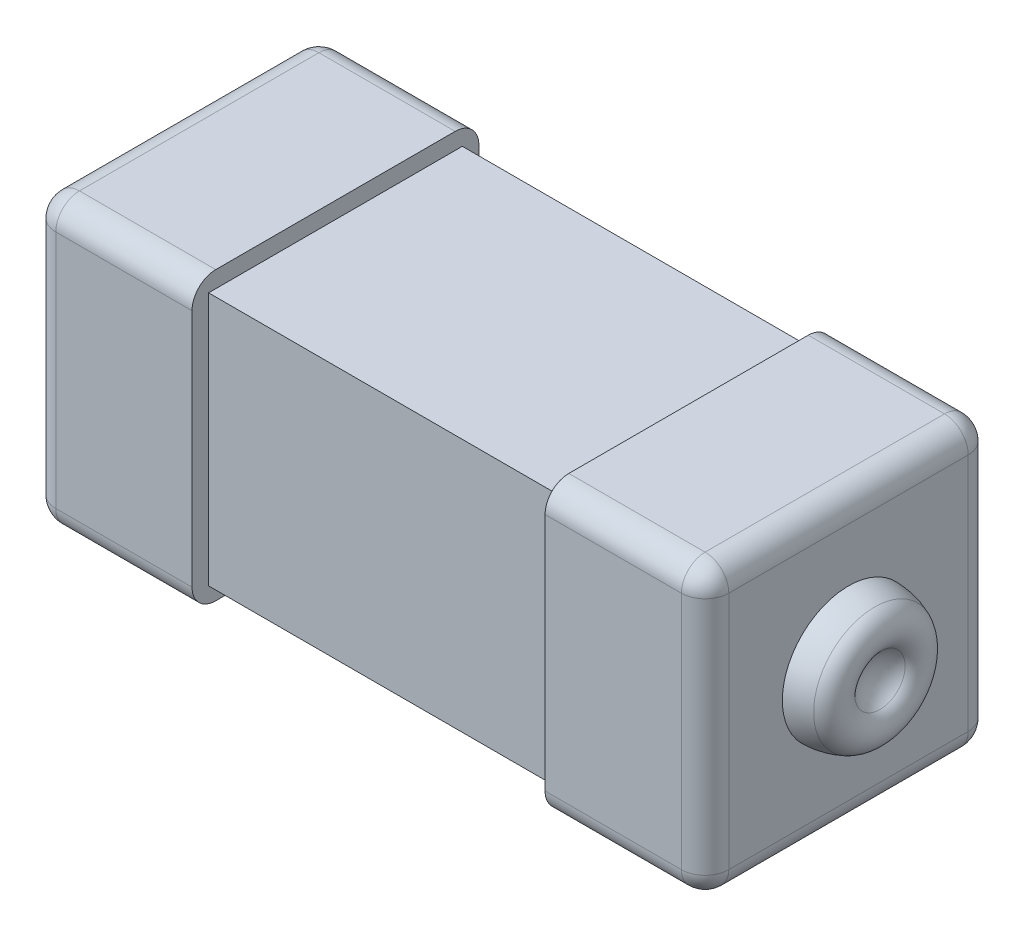
from build123d import *

# Parameters (mm, degrees)
SKETCH1_W            = 2.3
SKETCH1_H            = 2.3
BOSS_EXTRUDE1_DEPTH  = 1.6
SKETCH4_W            = 2.6
SKETCH4_H            = 2.6
BOSS_EXTRUDE2_DEPTH  = 1.45
FILLET1_R            = 0.215
FILLET1_OF_MIRROR2_R = 0.215


with BuildPart() as part:
    # Sketch1 → Boss-Extrude1 (new body, symmetric)
    with BuildSketch(Plane(origin=(0, 0, 0), x_dir=(0, 0, -1), z_dir=(1, 0, 0))):
        Rectangle(SKETCH1_W, SKETCH1_H)
    extrude(amount=BOSS_EXTRUDE1_DEPTH, both=True)

    # Sketch4 → Boss-Extrude2 (add)
    with BuildSketch(Plane(origin=(1.6, 0, 0), x_dir=(0, 0, -1), z_dir=(1, 0, 0))):
        Rectangle(SKETCH4_W, SKETCH4_H)
    boss_extrude2 = extrude(amount=BOSS_EXTRUDE2_DEPTH)

    # Sketch5 → Revolve4 (revolve)
    with BuildSketch(Plane(origin=(0, 0, 0), x_dir=(1, 0, 0), z_dir=(0, 1, 0))):
        with BuildLine():
            Line((3.05, 0.6), (3.05, 0))
            Line((3.05, 0), (3.23, 0))
            ThreePointArc((3.23, 0), (3.257550578, 0.125583887), (3.335142084, 0.228101715))
            ThreePointArc((3.335142084, 0.228101715), (3.40045563, 0.403698644), (3.285679214, 0.551774689))
            ThreePointArc((3.285679214, 0.551774689), (3.170281308, 0.587820046), (3.05, 0.6))
        make_face()
    revolve4 = revolve(axis=Axis((3.53, 0, 0), (-1, 0, 0)))

    # Fillet1
    fillet1_edges = [part.edges().sort_by_distance(p)[0] for p in [
        (2.325, 1.3, 1.3),
        (2.325, -1.3, 1.3),
        (2.325, -1.3, -1.3),
        (2.325, 1.3, -1.3),
        (3.05, 0, 1.3),
        (3.05, -1.3, 0),
        (3.05, 0, -1.3),
        (3.05, 1.3, 0),
    ]]
    fillet(fillet1_edges, radius=FILLET1_R)

    # Mirror2: Boss-Extrude2, Revolve4 across plane
    add(boss_extrude2.mirror(Plane(origin=(0, 0, 0), x_dir=(0, 0, 1), z_dir=(1, 0, 0))))
    add(revolve4.mirror(Plane(origin=(0, 0, 0), x_dir=(0, 0, 1), z_dir=(1, 0, 0))))

    # Fillet1 of Mirror2
    fillet1_of_mirror2_edges = [part.edges().sort_by_distance(p)[0] for p in [
        (-2.325, 1.3, 1.3),
        (-2.325, -1.3, 1.3),
        (-2.325, -1.3, -1.3),
        (-2.325, 1.3, -1.3),
        (-3.05, 0, 1.3),
        (-3.05, -1.3, 0),
        (-3.05, 0, -1.3),
        (-3.05, 1.3, 0),
    ]]
    fillet(fillet1_of_mirror2_edges, radius=FILLET1_OF_MIRROR2_R)


solid = part.part
